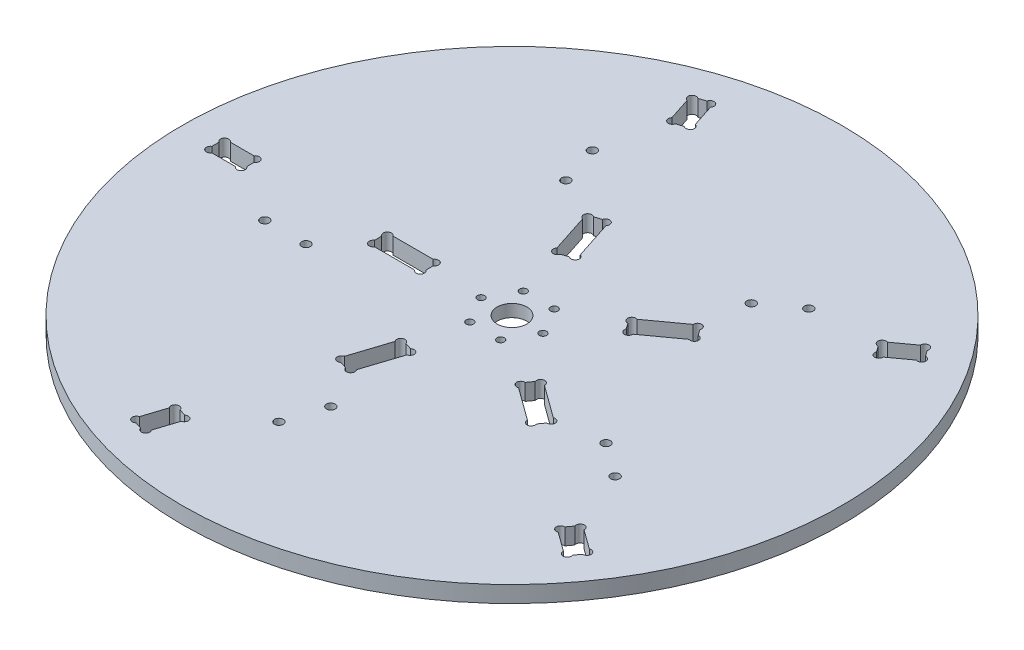
from build123d import *

# Parameters (mm, degrees)
SKETCH1_R                                = 254
BOSS_EXTRUDE1_DEPTH                      = 6.35
F_10_CLEARANCE_HOLE1_D                   = 5.6134
F_10_CLEARANCE_HOLE1_DEPTH               = 12.7
SKETCH3_W                                = 39.6875
SKETCH3_H                                = 14.2875
SKETCH3_W_2                              = 26.9875
CUT_EXTRUDE2_DEPTH                       = 13.7
F_1_4_CLEARANCE_HOLE1_D                  = 6.7564
F_1_4_0_2500_DOWEL_HOLE2_D               = 6.35
CIRPATTERN1_COUNT                        = 5
CBORE_FOR_1_4_HEX_HEAD_BOLT1_D           = 22.86
CBORE_FOR_1_4_HEX_HEAD_BOLT1_CBORE_D     = 31.75
CBORE_FOR_1_4_HEX_HEAD_BOLT1_CBORE_DEPTH = 3.175


with BuildPart() as part:
    # Sketch1 → Boss-Extrude1 (new body, symmetric)
    with BuildSketch(Plane(origin=(0, 0, 0), x_dir=(1, 0, 0), z_dir=(0, 1, 0))):
        Circle(SKETCH1_R)
    extrude(amount=BOSS_EXTRUDE1_DEPTH, both=True)

    # 10 Clearance Hole1
    with Locations(Plane(origin=(0, 6.35, 0), x_dir=(1, 0, 0), z_dir=(0, 1, 0))):
        with Locations((-11.90625, 20.622229928), (11.90625, 20.622229928), (23.8125, 0), (11.90625, -20.622229928), (-11.90625, -20.622229928), (-23.8125, 0)):
            Hole(F_10_CLEARANCE_HOLE1_D / 2, depth=F_10_CLEARANCE_HOLE1_DEPTH)

    # Sketch3 → Cut-Extrude2 (cut, through all)
    with BuildSketch(Plane(origin=(0, 6.35, 0), x_dir=(1, 0, 0), z_dir=(0, 1, 0))):
        with Locations((-83.34375, 0)):
            Rectangle(SKETCH3_W, SKETCH3_H)
        with Locations((-215.10625, 0)):
            Rectangle(SKETCH3_W_2, SKETCH3_H)
    cut_extrude2 = extrude(amount=-CUT_EXTRUDE2_DEPTH, mode=Mode.SUBTRACT)

    # 1_4 Clearance Hole1 (through all)
    with Locations(Plane(origin=(0, 6.35, 0), x_dir=(1, 0, 0), z_dir=(0, 1, 0))):
        with Locations((-158.75, -31.75), (-127, -31.75)):
            f_1_4_clearance_hole1 = Hole(F_1_4_CLEARANCE_HOLE1_D / 2)

    # 1_4 _0.2500_ Dowel Hole2 (through all)
    with Locations(Plane(origin=(0, 6.35, 0), x_dir=(1, 0, 0), z_dir=(0, 1, 0))):
        with Locations((-65.183798023, 5.459951977), (-65.183798023, -5.459951977), (-101.503701977, -5.459951977), (-101.503701977, 5.459951977), (-203.296298023, 5.459951977), (-203.296298023, -5.459951977), (-226.916201977, -5.459951977), (-226.916201977, 5.459951977)):
            f_1_4_0_2500_dowel_hole2 = Hole(F_1_4_0_2500_DOWEL_HOLE2_D / 2)

    # CirPattern1: Cut-Extrude2, 1_4 Clearance Hole1, 1_4 _0.2500_ Dowel Hole2 ×5 about axis
    cirpattern1_axis = Axis((0, 0, 0), (0, 1, 0))
    for i in range(1, CIRPATTERN1_COUNT):
        add(cut_extrude2.rotate(cirpattern1_axis, i * 360 / CIRPATTERN1_COUNT), mode=Mode.SUBTRACT)
        add(f_1_4_clearance_hole1.rotate(cirpattern1_axis, i * 360 / CIRPATTERN1_COUNT), mode=Mode.SUBTRACT)
        add(f_1_4_0_2500_dowel_hole2.rotate(cirpattern1_axis, i * 360 / CIRPATTERN1_COUNT), mode=Mode.SUBTRACT)

    # CBORE for 1_4 Hex Head Bolt1 (through all)
    with Locations(Plane.XZ.offset(6.35)):
        with Locations((0, 0)):
            CounterBoreHole(CBORE_FOR_1_4_HEX_HEAD_BOLT1_D / 2, CBORE_FOR_1_4_HEX_HEAD_BOLT1_CBORE_D / 2, CBORE_FOR_1_4_HEX_HEAD_BOLT1_CBORE_DEPTH)


solid = part.part
